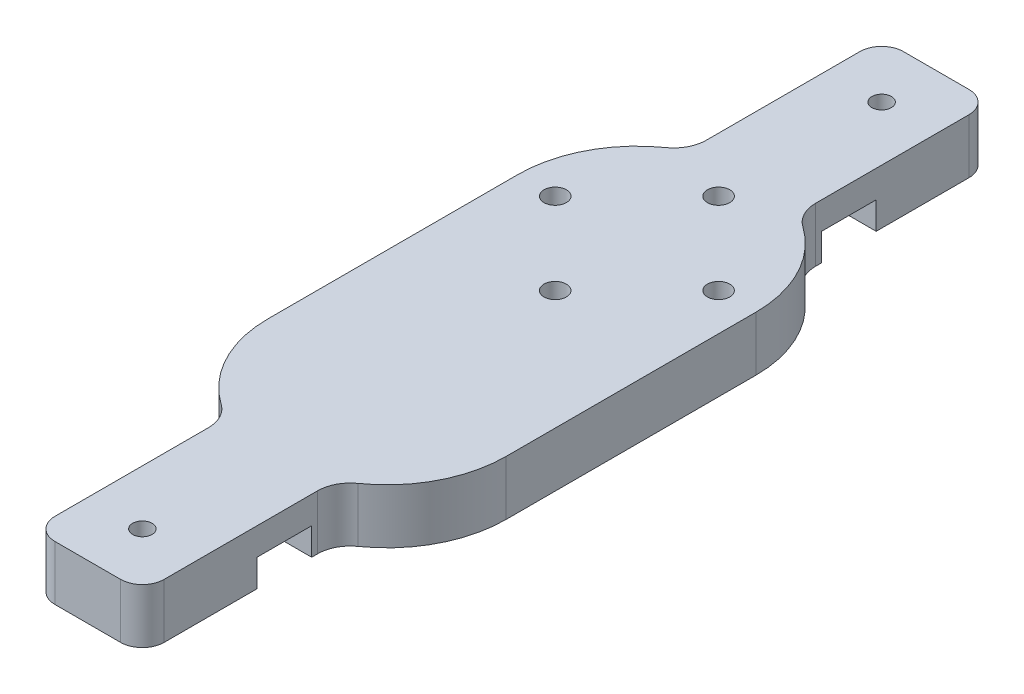
from build123d import *

# Parameters (mm, degrees)
BOSS_EXTRUDE1_DEPTH   = 6.35
SKETCH3_W             = 12.7
SKETCH3_H             = 6.35
SKETCH3_R             = 1.651
CUT_EXTRUDE2_DEPTH    = 3.175
F_4_40_TAPPED_HOLE1_D = 2.2606
M2_CLEARANCE_HOLE1_D  = 2.6
FILLET1_R             = 3.81


with BuildPart() as part:
    # Sketch1 → Boss-Extrude1 (new body)
    with BuildSketch(Plane(origin=(0, 0, 0), x_dir=(1, 0, 0), z_dir=(0, 1, 0))):
        with BuildLine():
            Line((13.850000078, -23.754236173), (13.850000078, 5.291734921))
            ThreePointArc((13.850000078, 5.291734921), (11.827298987, 12.498502631), (6.35, 17.600268634))
            Line((6.35, 17.600268634), (6.35, 37.56114916))
            ThreePointArc((6.35, 37.56114916), (5.606051224, 39.357200384), (3.81, 40.10114916))
            Line((3.81, 40.10114916), (-3.81, 40.10114916))
            ThreePointArc((-3.81, 40.10114916), (-5.606051224, 39.357200384), (-6.35, 37.56114916))
            Line((-6.35, 37.56114916), (-6.35, 17.600268634))
            ThreePointArc((-6.35, 17.600268634), (-11.827298987, 12.498502631), (-13.850000078, 5.291734921))
            Line((-13.850000078, 5.291734921), (-13.850000078, -23.754236173))
            ThreePointArc((-13.850000078, -23.754236173), (-11.827298987, -30.961003884), (-6.35, -36.062769886))
            Line((-6.35, -36.062769886), (-6.35, -56.023651732))
            ThreePointArc((-6.35, -56.023651732), (-5.606051224, -57.819702956), (-3.81, -58.563651732))
            Line((-3.81, -58.563651732), (3.81, -58.563651732))
            ThreePointArc((3.81, -58.563651732), (5.606051224, -57.819702956), (6.35, -56.023651732))
            Line((6.35, -56.023651732), (6.35, -36.062769886))
            ThreePointArc((6.35, -36.062769886), (11.827298987, -30.961003884), (13.850000078, -23.754236173))
        make_face()
    extrude(amount=BOSS_EXTRUDE1_DEPTH)

    # Sketch3 → Cut-Extrude2 (cut)
    with BuildSketch(Plane.XZ):
        with Locations((0, -23.59114916)):
            Rectangle(SKETCH3_W, SKETCH3_H)
        with Locations((0, -23.59114916)):
            Circle(SKETCH3_R, mode=Mode.SUBTRACT)
        with Locations((0, -23.59114916)):
            Circle(SKETCH3_R)
        with Locations((0, 42.053651732)):
            Rectangle(SKETCH3_W, SKETCH3_H)
        with Locations((0, 42.053651732)):
            Circle(SKETCH3_R, mode=Mode.SUBTRACT)
        with Locations((0, 42.053651732)):
            Circle(SKETCH3_R)
    extrude(amount=-CUT_EXTRUDE2_DEPTH, mode=Mode.SUBTRACT)

    # #4-40 Tapped Hole1 (through all)
    with Locations(Plane(origin=(0, 0, 0), x_dir=(-1, 0, 0), z_dir=(0, -1, 0))):
        with Locations((0, -52.213651732), (0, 33.75114916)):
            Hole(F_4_40_TAPPED_HOLE1_D / 2)

    # M2 Clearance Hole1 (through all)
    with Locations(Plane(origin=(0, 0, 0), x_dir=(-1, 0, 0), z_dir=(0, -1, 0))):
        with Locations((9.50000005, 5.291734921), (0, 14.791734971), (-9.50000005, 5.291734921), (0, -4.208265129)):
            Hole(M2_CLEARANCE_HOLE1_D / 2)

    # Fillet1
    fillet1_edges = [part.edges().sort_by_distance(p)[0] for p in [
        (-6.35, 3.175, 36.062769886),
        (-6.35, 3.175, -17.600268634),
        (6.35, 3.175, -17.600268634),
        (6.35, 3.175, 36.062769886),
    ]]
    fillet(fillet1_edges, radius=FILLET1_R)


solid = part.part
